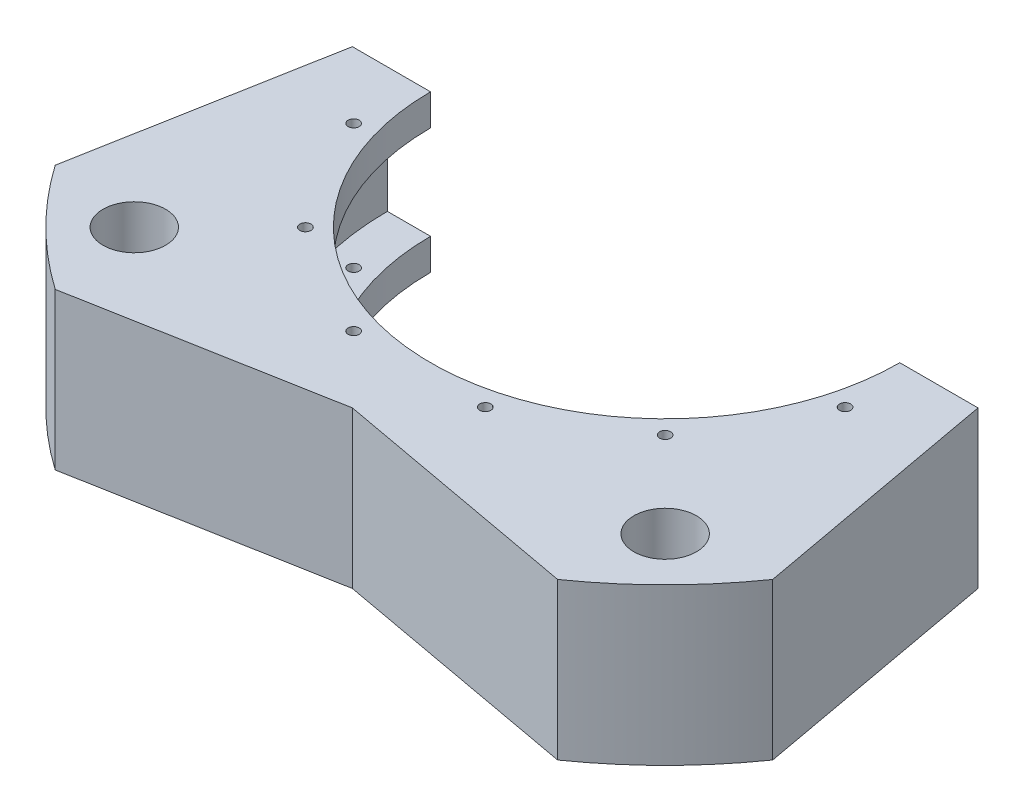
from build123d import *

# Parameters (mm, degrees)
REVOLVE1_ANGLE                 = 180
TAP_DRILL_FOR_4_40_TAP1_D      = 2.2606
CIRPATTERN1_COUNT              = 12
CUT_EXTRUDE1_REACH             = 90.9
SKETCH4_R                      = 1.1303
CUT_EXTRUDE2_REACH             = 90.9
SKETCH6_R                      = 1.1303
CUT_EXTRUDE2_DIRECTION_2_DEPTH = 1.0000001
CUT_EXTRUDE3_REACH             = 33.75
SKETCH7_R                      = 6.35


with BuildPart() as part:
    # Sketch1 → Revolve1 (revolve)
    with BuildSketch(Plane.XY):
        Polygon((56.388, 0), (56.388, 9.525), (47.625, 9.525), (47.625, 15.875), (88.9, 15.875), (88.9, -15.875), (47.625, -15.875), (47.625, -9.525), (56.388, -9.525), align=None)
    revolve(axis=Axis((0, 22.539286723, 0), (0, -1, 0)), revolution_arc=REVOLVE1_ANGLE)

    # Tap Drill for #4-40 Tap1 (through all)
    with Locations(Plane(origin=(49.878671003, 15.875, 13.364949615), x_dir=(0, 0, 1), z_dir=(0, 1, 0))):
        with Locations((0, 0)):
            tap_drill_for_4_40_tap1 = Hole(TAP_DRILL_FOR_4_40_TAP1_D / 2)

    # CirPattern1: Tap Drill for #4-40 Tap1 ×12 about axis, 6 skipped
    cirpattern1_axis = Axis((0, 15.875, 0), (0, 1, 0))
    add([tap_drill_for_4_40_tap1.rotate(cirpattern1_axis, i * 360 / CIRPATTERN1_COUNT) for i in range(1, CIRPATTERN1_COUNT) if i not in (1, 2, 3, 4, 5, 6)], mode=Mode.SUBTRACT)

    # Sketch4 → Cut-Extrude1 (cut, up to next)
    with BuildSketch(Plane(origin=(0, 0, 0), x_dir=(-1, 0, 0), z_dir=(0, 0, -1)), mode=Mode.PRIVATE) as cut_extrude1_sk1:
        with Locations((82.55, 6.35)):
            Circle(SKETCH4_R)
    cut_extrude1_tool1 = extrude(cut_extrude1_sk1.sketch, amount=-CUT_EXTRUDE1_REACH, mode=Mode.PRIVATE) & part.part
    add(cut_extrude1_tool1.solids().sort_by_distance((-82.55, 6.35, 0))[0], mode=Mode.SUBTRACT)
    # Sketch4 → Cut-Extrude1 (cut, up to next)
    with BuildSketch(Plane(origin=(0, 0, 0), x_dir=(-1, 0, 0), z_dir=(0, 0, -1)), mode=Mode.PRIVATE) as cut_extrude1_sk2:
        with Locations((82.55, -6.35)):
            Circle(SKETCH4_R)
    cut_extrude1_tool2 = extrude(cut_extrude1_sk2.sketch, amount=-CUT_EXTRUDE1_REACH, mode=Mode.PRIVATE) & part.part
    add(cut_extrude1_tool2.solids().sort_by_distance((-82.55, -6.35, 0))[0], mode=Mode.SUBTRACT)

    # Sketch6 → Cut-Extrude2 (cut, up to next)
    with BuildSketch(Plane(origin=(0, 0, 0), x_dir=(-1, 0, 0), z_dir=(0, 0, -1)), mode=Mode.PRIVATE) as cut_extrude2_sk1:
        with Locations((-82.55, 6.35)):
            Circle(SKETCH6_R)
    cut_extrude2_tool1 = extrude(cut_extrude2_sk1.sketch, amount=-CUT_EXTRUDE2_REACH, mode=Mode.PRIVATE) & part.part
    add(cut_extrude2_tool1.solids().sort_by_distance((82.55, 6.35, 0))[0], mode=Mode.SUBTRACT)
    # Sketch6 → Cut-Extrude2 (cut, up to next)
    with BuildSketch(Plane(origin=(0, 0, 0), x_dir=(-1, 0, 0), z_dir=(0, 0, -1)), mode=Mode.PRIVATE) as cut_extrude2_sk2:
        with Locations((-82.579243869, -6.35)):
            Circle(SKETCH6_R)
    cut_extrude2_tool2 = extrude(cut_extrude2_sk2.sketch, amount=-CUT_EXTRUDE2_REACH, mode=Mode.PRIVATE) & part.part
    add(cut_extrude2_tool2.solids().sort_by_distance((82.579244, -6.35, 0))[0], mode=Mode.SUBTRACT)

    # Sketch6 → Cut-Extrude2 direction 2 (cut)
    with BuildSketch(Plane(origin=(0, 0, 0), x_dir=(-1, 0, 0), z_dir=(0, 0, -1))):
        with Locations((-82.55, 6.35)):
            Circle(SKETCH6_R)
        with Locations((-82.579243869, -6.35)):
            Circle(SKETCH6_R)
    extrude(amount=CUT_EXTRUDE2_DIRECTION_2_DEPTH, mode=Mode.SUBTRACT)

    # Sketch7 → Cut-Extrude3 (cut, up to next)
    with BuildSketch(Plane(origin=(0, 15.875, 0), x_dir=(1, 0, 0), z_dir=(0, 1, 0)), mode=Mode.PRIVATE) as cut_extrude3_sk1:
        with Locations((53.881536726, -53.881536726)):
            Circle(SKETCH7_R)
    cut_extrude3_tool1 = extrude(cut_extrude3_sk1.sketch, amount=-CUT_EXTRUDE3_REACH, mode=Mode.PRIVATE) & part.part
    add(cut_extrude3_tool1.solids().sort_by_distance((53.881537, 15.875, 53.881537))[0], mode=Mode.SUBTRACT)
    # Sketch7 → Cut-Extrude3 (cut, up to next)
    with BuildSketch(Plane(origin=(0, 15.875, 0), x_dir=(1, 0, 0), z_dir=(0, 1, 0)), mode=Mode.PRIVATE) as cut_extrude3_sk2:
        with Locations((-53.881536726, -53.881536726)):
            Circle(SKETCH7_R)
    cut_extrude3_tool2 = extrude(cut_extrude3_sk2.sketch, amount=-CUT_EXTRUDE3_REACH, mode=Mode.PRIVATE) & part.part
    add(cut_extrude3_tool2.solids().sort_by_distance((-53.881537, 15.875, 53.881537))[0], mode=Mode.SUBTRACT)
    # Sketch7 → Cut-Extrude3 (cut, up to next)
    with BuildSketch(Plane(origin=(0, 15.875, 0), x_dir=(1, 0, 0), z_dir=(0, 1, 0)), mode=Mode.PRIVATE) as cut_extrude3_sk3:
        with BuildLine():
            ThreePointArc((-50.990945192, -72.822616737), (0, -88.9), (50.990945192, -72.822616737))
            Line((50.990945192, -72.822616737), (0, -63.5))
            Line((0, -63.5), (-50.990945192, -72.822616737))
        make_face()
    cut_extrude3_tool3 = extrude(cut_extrude3_sk3.sketch, amount=-CUT_EXTRUDE3_REACH, mode=Mode.PRIVATE) & part.part
    add(cut_extrude3_tool3.solids().sort_by_distance((0, 15.875, 76.438451))[0], mode=Mode.SUBTRACT)
    # Sketch7 → Cut-Extrude3 (cut, up to next)
    with BuildSketch(Plane(origin=(0, 15.875, 0), x_dir=(1, 0, 0), z_dir=(0, 1, 0)), mode=Mode.PRIVATE) as cut_extrude3_sk4:
        with BuildLine():
            Line((63.5, 0), (72.822616737, -50.990945192))
            ThreePointArc((72.822616737, -50.990945192), (84.785436922, -26.732745576), (88.9, 0))
            Line((88.9, 0), (63.5, 0))
        make_face()
    cut_extrude3_tool4 = extrude(cut_extrude3_sk4.sketch, amount=-CUT_EXTRUDE3_REACH, mode=Mode.PRIVATE) & part.part
    add(cut_extrude3_tool4.solids().sort_by_distance((76.438451, 15.875, 18.664198))[0], mode=Mode.SUBTRACT)
    # Sketch7 → Cut-Extrude3 (cut, up to next)
    with BuildSketch(Plane(origin=(0, 15.875, 0), x_dir=(1, 0, 0), z_dir=(0, 1, 0)), mode=Mode.PRIVATE) as cut_extrude3_sk5:
        with BuildLine():
            Line((-72.822616737, -50.990945192), (-63.5, 0))
            Line((-63.5, 0), (-88.9, 0))
            ThreePointArc((-88.9, 0), (-84.785436922, -26.732745576), (-72.822616737, -50.990945192))
        make_face()
    cut_extrude3_tool5 = extrude(cut_extrude3_sk5.sketch, amount=-CUT_EXTRUDE3_REACH, mode=Mode.PRIVATE) & part.part
    add(cut_extrude3_tool5.solids().sort_by_distance((-76.438451, 15.875, 18.664198))[0], mode=Mode.SUBTRACT)


solid = part.part
